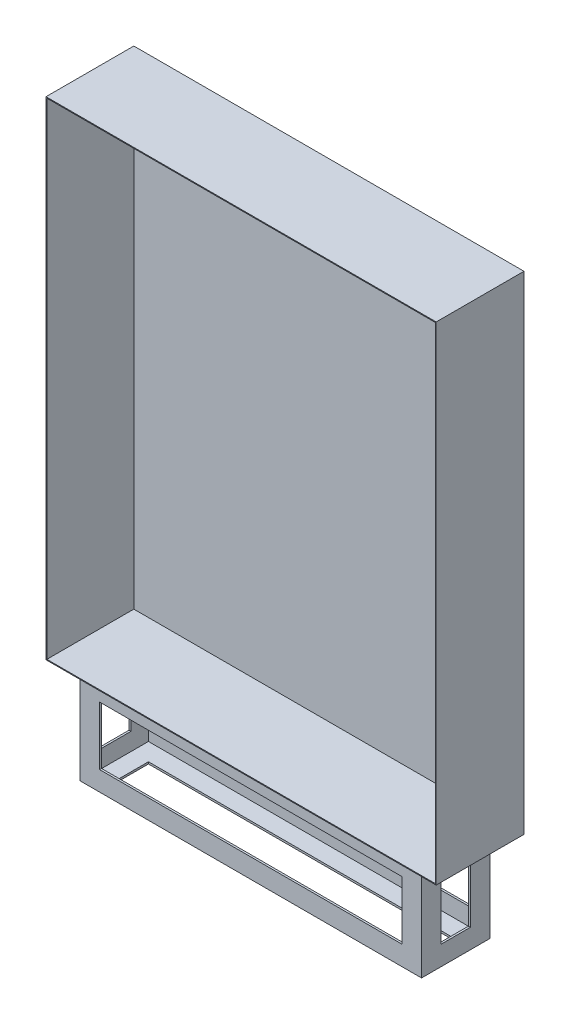
from build123d import *

# Parameters (mm, degrees)
SKETCH_1_W          = 800
SKETCH_1_H          = 1000
EXTRUDE_1_DEPTH     = 180
SHELL_1_T           = -1.8
SKETCH_2_W          = 700
SKETCH_2_H          = 140
SKETCH_2_W_2        = 692
SKETCH_2_H_2        = 132
EXTRUDE_2_DEPTH     = 200
SKETCH_3_W          = 700
SKETCH_3_H          = 140
SKETCH_3_W_2        = 620
SKETCH_3_H_2        = 60
EXTRUDE_3_DEPTH     = 4
SKETCH_4_W          = 620
SKETCH_4_H          = 120
CUT_EXTRUDE_1_DEPTH = 140
SKETCH_5_W          = 60
SKETCH_5_H          = 120
CUT_EXTRUDE_2_DEPTH = 700


with BuildPart() as part:
    # 草图1 → 凸台-拉伸1 (new body)
    with BuildSketch(Plane.XY):
        with Locations((400, 500)):
            Rectangle(SKETCH_1_W, SKETCH_1_H)
    extrude(amount=EXTRUDE_1_DEPTH)

    # 抽壳1
    shell_1_openings = [part.faces().sort_by_distance(p)[0] for p in [
        (400, 500, 180),
    ]]
    offset(amount=SHELL_1_T, openings=shell_1_openings, kind=Kind.INTERSECTION)

    # 草图2 → 凸台-拉伸2 (add)
    with BuildSketch(Plane.XZ):
        with Locations((400, 90)):
            Rectangle(SKETCH_2_W, SKETCH_2_H)
        with Locations((400, 90)):
            Rectangle(SKETCH_2_W_2, SKETCH_2_H_2, mode=Mode.SUBTRACT)
    extrude(amount=EXTRUDE_2_DEPTH)

    # 草图3 → 凸台-拉伸3 (add)
    with BuildSketch(Plane.XZ.offset(200)):
        with Locations((400, 90)):
            Rectangle(SKETCH_3_W, SKETCH_3_H)
        with Locations((400, 90)):
            Rectangle(SKETCH_3_W_2, SKETCH_3_H_2, mode=Mode.SUBTRACT)
    extrude(amount=-EXTRUDE_3_DEPTH)

    # 草图4 → 切除-拉伸1 (cut)
    with BuildSketch(Plane(origin=(0, 0, 20), x_dir=(-1, 0, 0), z_dir=(0, 0, -1))):
        with Locations((-400, -100)):
            Rectangle(SKETCH_4_W, SKETCH_4_H)
    extrude(amount=-CUT_EXTRUDE_1_DEPTH, mode=Mode.SUBTRACT)

    # 草图5 → 切除-拉伸2 (cut)
    with BuildSketch(Plane(origin=(750, 0, 0), x_dir=(0, 0, -1), z_dir=(1, 0, 0))):
        with Locations((-90, -100)):
            Rectangle(SKETCH_5_W, SKETCH_5_H)
    extrude(amount=-CUT_EXTRUDE_2_DEPTH, mode=Mode.SUBTRACT)


solid = part.part
